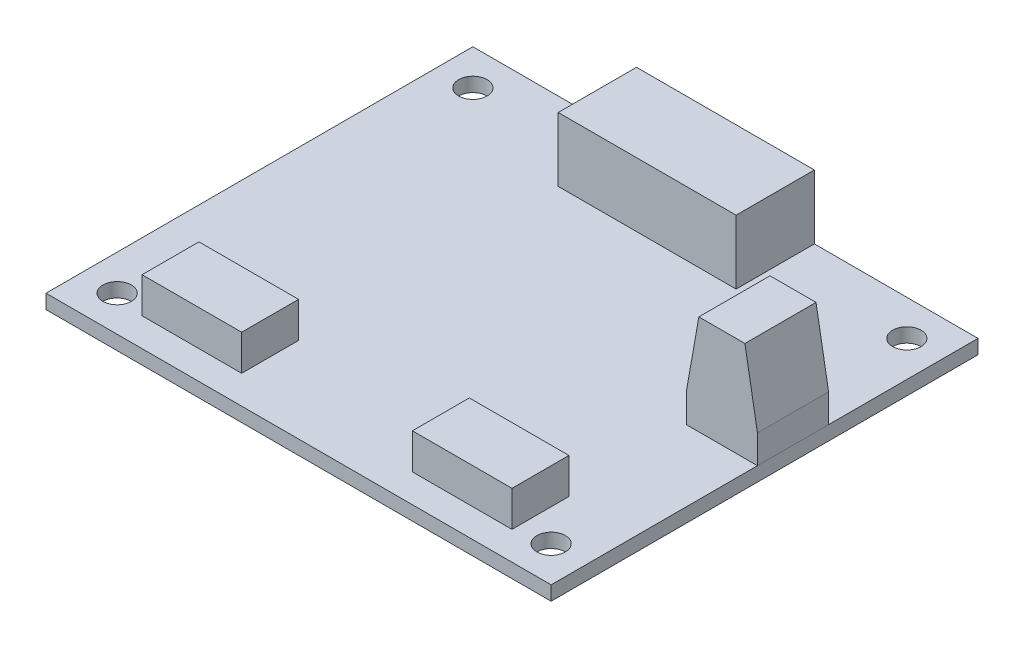
from build123d import *

# Parameters (mm, degrees)
SKETCH1_W             = 71
SKETCH1_H             = 60
BOSS_EXTRUDE1_DEPTH   = 2
SKETCH2_W             = 25
SKETCH2_H             = 11
BOSS_EXTRUDE2_DEPTH   = 9
SKETCH2_3_W           = 10
SKETCH2_3_H           = 10
BOSS_EXTRUDE3_DEPTH   = 14
CHAMFER1_SIZE         = 10
CHAMFER1_SIZE2        = 1.763269807
CHAMFER1_PART_2_SIZE  = 10
CHAMFER1_PART_2_SIZE2 = 1.763269807
SKETCH2_5_R           = 2
CUT_EXTRUDE2_DEPTH    = 2
SKETCH2_6_W           = 14
SKETCH2_6_H           = 8
BOSS_EXTRUDE4_DEPTH   = 5


with BuildPart() as part:
    # Sketch1 → Boss-Extrude1 (new body)
    with BuildSketch(Plane(origin=(0, 0, 0), x_dir=(1, 0, 0), z_dir=(0, 1, 0))):
        with Locations((35.5, 30)):
            Rectangle(SKETCH1_W, SKETCH1_H)
    extrude(amount=BOSS_EXTRUDE1_DEPTH)

    # Sketch2_5 → Cut-Extrude2 (cut)
    with BuildSketch(Plane(origin=(0, 2, 0), x_dir=(1, 0, 0), z_dir=(0, 1, 0))):
        with Locations((5, 55)):
            Circle(SKETCH2_5_R)
        with Locations((5, 5)):
            Circle(SKETCH2_5_R)
        with Locations((66, 5)):
            Circle(SKETCH2_5_R)
        with Locations((66, 55)):
            Circle(SKETCH2_5_R)
    extrude(amount=-CUT_EXTRUDE2_DEPTH, mode=Mode.SUBTRACT)

    # Sketch2_6 → Boss-Extrude4 (add)
    with BuildSketch(Plane(origin=(0, 2, 0), x_dir=(1, 0, 0), z_dir=(0, 1, 0))):
        with Locations((16.5, 8)):
            Rectangle(SKETCH2_6_W, SKETCH2_6_H)
        with Locations((54.5, 8)):
            Rectangle(SKETCH2_6_W, SKETCH2_6_H)
    extrude(amount=BOSS_EXTRUDE4_DEPTH)


with BuildPart() as body_2:
    # Sketch2 → Boss-Extrude2 (new body)
    with BuildSketch(Plane(origin=(0, 2, 0), x_dir=(1, 0, 0), z_dir=(0, 1, 0))):
        with Locations((35.5, 54.5)):
            Rectangle(SKETCH2_W, SKETCH2_H)
    extrude(amount=BOSS_EXTRUDE2_DEPTH)


with BuildPart() as body_3:
    # Sketch2_3 → Boss-Extrude3 (new body)
    with BuildSketch(Plane(origin=(0, 2, 0), x_dir=(1, 0, 0), z_dir=(0, 1, 0))):
        with Locations((66, 34)):
            Rectangle(SKETCH2_3_W, SKETCH2_3_H)
    extrude(amount=BOSS_EXTRUDE3_DEPTH)

    # Chamfer1
    chamfer1_edges = [body_3.edges().sort_by_distance(p)[0] for p in [
        (71, 16, -34),
    ]]
    chamfer1_side = [body_3.faces().sort_by_distance(p)[0] for p in [
        (71, 9, -34),
    ]]
    chamfer(chamfer1_edges, length=CHAMFER1_SIZE, length2=CHAMFER1_SIZE2, reference=chamfer1_side[0])

    # Chamfer1 part 2
    chamfer1_part_2_edges = [body_3.edges().sort_by_distance(p)[0] for p in [
        (61, 16, -34),
    ]]
    chamfer1_part_2_side = [body_3.faces().sort_by_distance(p)[0] for p in [
        (61, 9, -34),
    ]]
    chamfer(chamfer1_part_2_edges, length=CHAMFER1_PART_2_SIZE, length2=CHAMFER1_PART_2_SIZE2, reference=chamfer1_part_2_side[0])


solid = Compound([part.part, body_2.part, body_3.part])
